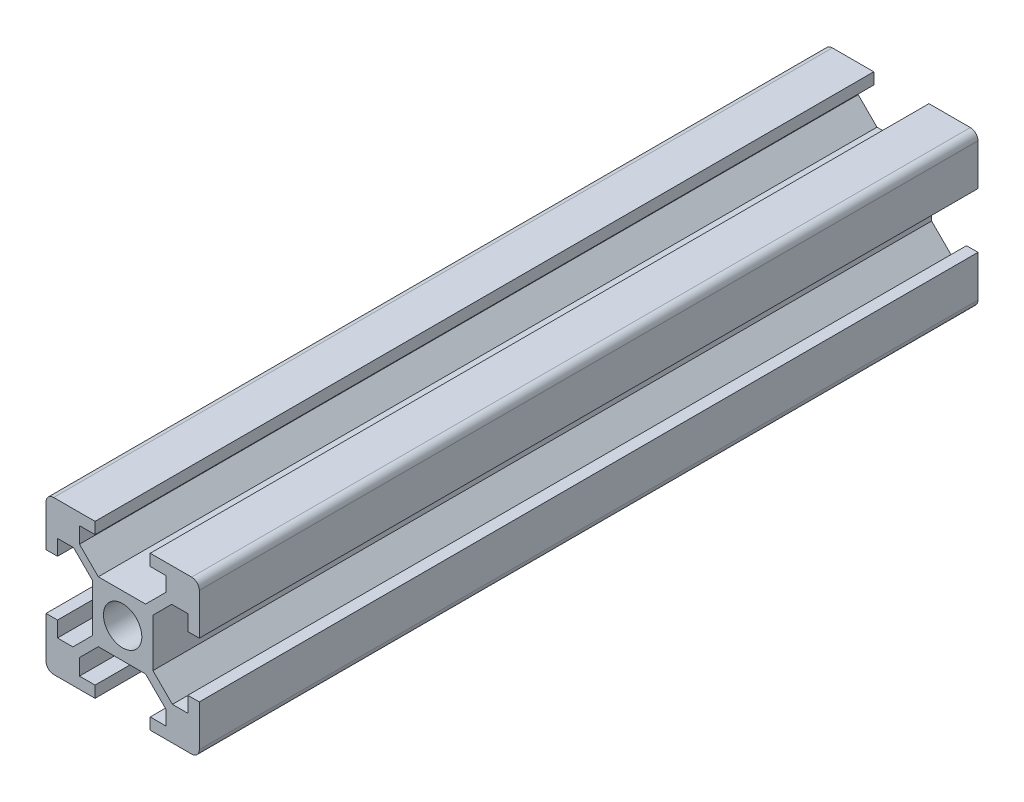
from build123d import *

# Parameters (mm, degrees)
SKETCH1_R           = 2.5
BOSS_EXTRUDE1_DEPTH = 482.6
SKETCH2_W           = 35.989521226
SKETCH2_H           = 397.523683421
CUT_EXTRUDE1_DEPTH  = 21


with BuildPart() as part:
    # Sketch1 → Boss-Extrude1 (new body)
    with BuildSketch(Plane.XY):
        with BuildLine():
            Line((-5.63, 10), (-9, 10))
            ThreePointArc((-9, 10), (-9.707106781, 9.707106781), (-10, 9))
            Line((-10, 9), (-10, 5.63))
            Line((-10, 5.63), (-10, 3.6))
            Line((-10, 3.6), (-8.5, 3.6))
            Line((-8.5, 3.6), (-8.5, 5.63))
            Line((-8.5, 5.63), (-6.402046573, 5.63))
            Line((-6.402046573, 5.63), (-3.95, 3.177953427))
            Line((-3.95, 3.177953427), (-3.95, -3.088580227))
            Line((-3.95, -3.088580227), (-6.491419773, -5.63))
            Line((-6.491419773, -5.63), (-8.5, -5.63))
            Line((-8.5, -5.63), (-8.5, -3.6))
            Line((-8.5, -3.6), (-10, -3.6))
            Line((-10, -3.6), (-10, -5.63))
            Line((-10, -5.63), (-10, -9))
            ThreePointArc((-10, -9), (-9.707106781, -9.707106781), (-9, -10))
            Line((-9, -10), (-5.63, -10))
            Line((-5.63, -10), (-3.6, -10))
            Line((-3.6, -10), (-3.6, -8.5))
            Line((-3.6, -8.5), (-5.63, -8.5))
            Line((-5.63, -8.5), (-5.63, -6.402046573))
            Line((-5.63, -6.402046573), (-3.177953427, -3.95))
            Line((-3.177953427, -3.95), (2.991333041, -3.95))
            Line((2.991333041, -3.95), (5.63, -6.588666959))
            Line((5.63, -6.588666959), (5.63, -8.5))
            Line((5.63, -8.5), (3.6, -8.5))
            Line((3.6, -8.5), (3.6, -10))
            Line((3.6, -10), (5.63, -10))
            Line((5.63, -10), (9, -10))
            ThreePointArc((9, -10), (9.707106781, -9.707106781), (10, -9))
            Line((10, -9), (10, -5.63))
            Line((10, -5.63), (10, -3.6))
            Line((10, -3.6), (8.5, -3.6))
            Line((8.5, -3.6), (8.5, -5.63))
            Line((8.5, -5.63), (6.491419773, -5.63))
            Line((6.491419773, -5.63), (3.95, -3.088580227))
            Line((3.95, -3.088580227), (3.95, 3.177953427))
            Line((3.95, 3.177953427), (6.402046573, 5.63))
            Line((6.402046573, 5.63), (8.5, 5.63))
            Line((8.5, 5.63), (8.5, 3.6))
            Line((8.5, 3.6), (10, 3.6))
            Line((10, 3.6), (10, 5.63))
            Line((10, 5.63), (10, 9))
            ThreePointArc((10, 9), (9.707106781, 9.707106781), (9, 10))
            Line((9, 10), (5.63, 10))
            Line((5.63, 10), (3.6, 10))
            Line((3.6, 10), (3.6, 8.5))
            Line((3.6, 8.5), (5.63, 8.5))
            Line((5.63, 8.5), (5.63, 6.588666959))
            Line((5.63, 6.588666959), (2.991333041, 3.95))
            Line((2.991333041, 3.95), (-3.177953427, 3.95))
            Line((-3.177953427, 3.95), (-5.63, 6.402046573))
            Line((-5.63, 6.402046573), (-5.63, 8.5))
            Line((-5.63, 8.5), (-3.6, 8.5))
            Line((-3.6, 8.5), (-3.6, 10))
            Line((-3.6, 10), (-5.63, 10))
        make_face()
        Circle(SKETCH1_R, mode=Mode.SUBTRACT)
    extrude(amount=BOSS_EXTRUDE1_DEPTH)

    # Sketch2 → Cut-Extrude1 (cut, through all)
    with BuildSketch(Plane(origin=(0, 10, 0), x_dir=(1, 0, 0), z_dir=(0, 1, 0))):
        with Locations((3.85907628, -300.361841711)):
            Rectangle(SKETCH2_W, SKETCH2_H)
    extrude(amount=-CUT_EXTRUDE1_DEPTH, mode=Mode.SUBTRACT)


solid = part.part
